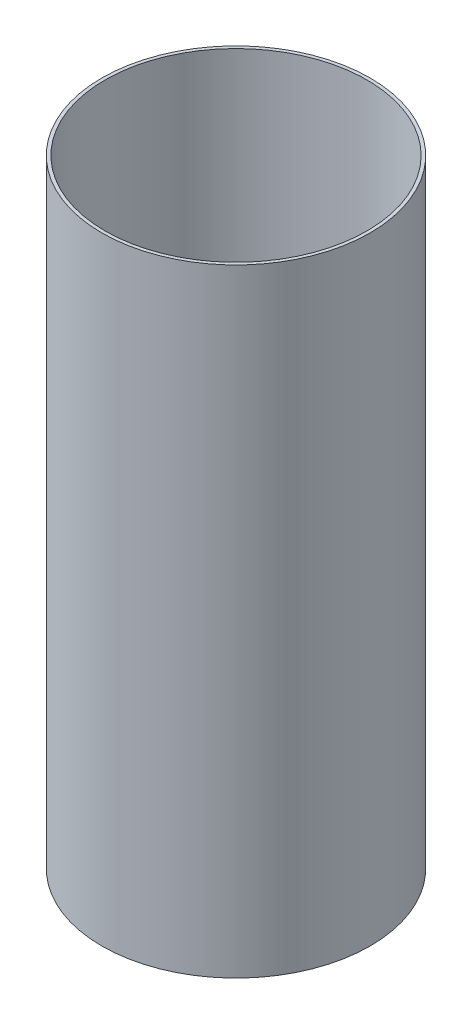
from build123d import *

# Parameters (mm, degrees)
SKETCH1_R           = 82.55
SKETCH1_R_2         = 76.55
BOSS_EXTRUDE1_DEPTH = 380
SKETCH2_R           = 80.55
CUT_EXTRUDE1_DEPTH  = 170
SKETCH3_R           = 80.55
CUT_EXTRUDE2_DEPTH  = 155


with BuildPart() as part:
    # Sketch1 → Boss-Extrude1 (new body)
    with BuildSketch(Plane(origin=(0, 0, 0), x_dir=(1, 0, 0), z_dir=(0, 1, 0))):
        Circle(SKETCH1_R)
        Circle(SKETCH1_R_2, mode=Mode.SUBTRACT)
    extrude(amount=BOSS_EXTRUDE1_DEPTH)

    # Sketch2 → Cut-Extrude1 (cut)
    with BuildSketch(Plane.XZ):
        Circle(SKETCH2_R)
    extrude(amount=-CUT_EXTRUDE1_DEPTH, mode=Mode.SUBTRACT)

    # Sketch3 → Cut-Extrude2 (cut)
    with BuildSketch(Plane(origin=(0, 380, 0), x_dir=(1, 0, 0), z_dir=(0, 1, 0))):
        Circle(SKETCH3_R)
    extrude(amount=-CUT_EXTRUDE2_DEPTH, mode=Mode.SUBTRACT)


solid = part.part
